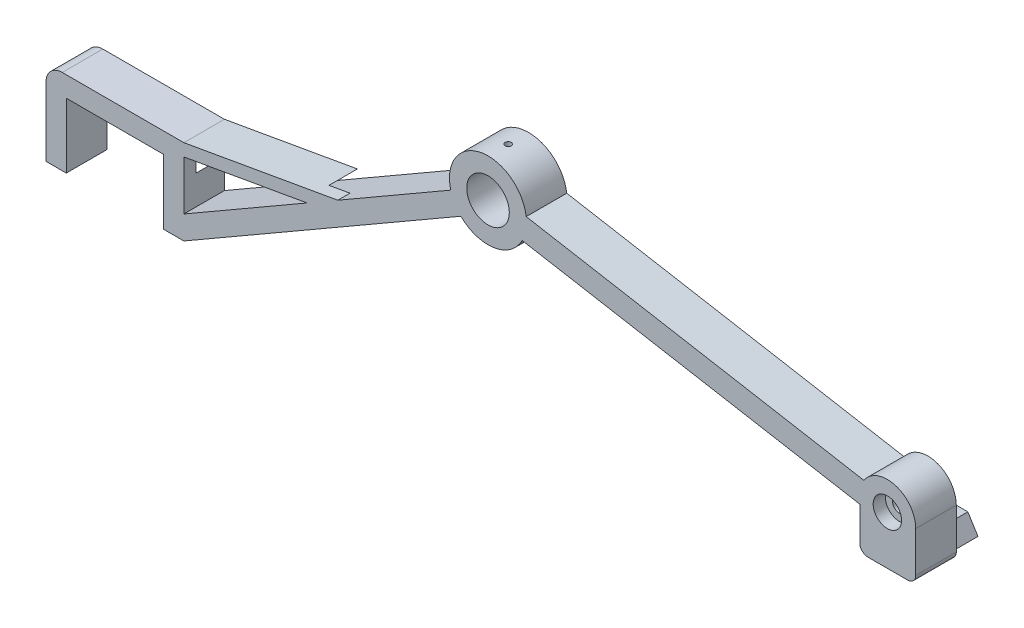
from build123d import *

# Parameters (mm, degrees)
SKICA1_R                 = 5.25
P_IDAT_VYSUNUT_M1_DEPTH  = 5
ZAOBLIT1_R               = 4
P_IDAT_VYSUNUT_M3_DEPTH  = 5
SKICA5_R                 = 4.25
SKICA5_R_2               = 1.75
P_IDAT_VYSUNUT_M4_DEPTH  = 1
SKICA8_R                 = 1.05
ODEBRAT_VYSUNUT_M3_DEPTH = 6
ODEBRAT_VYSUNUT_M4_DEPTH = 7
SKICA2_R                 = 1.75
ODEBRAT_VYSUNUT_M5_DEPTH = 10
SKICA10_R                = 3.5
ODEBRAT_VYSUNUT_M6_DEPTH = 3
ODEBRAT_START            = 50
SKICA11_R                = 0.75
ODEBRAT_VYSUNUT_M7_DEPTH = 10
P_IDAT_VYSUNUT_M5_DEPTH  = 10
P_IDAT_VYSUNUT_M6_DEPTH  = 8
ZAOBLIT2_R               = 2
ODEBRAT_VYSUNUT_M8_DEPTH = 7


with BuildPart() as part:
    # Skica1 → Přidat vysunutím1 (new body, symmetric)
    with BuildSketch(Plane.XY):
        with BuildLine():
            Line((0, 0), (0, 16))
            Line((0, 16), (24, 16))
            Line((24, 16), (24, 0))
            Line((24, 0), (29, 0))
            Line((29, 0), (97.312746067, 39.440382331))
            ThreePointArc((97.312746067, 39.440382331), (105.473420704, 36.802978572), (112.433277726, 41.81425579))
            Line((112.433277726, 41.81425579), (195.687578405, 27.134276321))
            ThreePointArc((195.687578405, 27.134276321), (209.374429572, 27.607666525), (196.674905514, 32.733686604))
            Line((196.674905514, 32.733686604), (113.420604835, 47.413666074))
            ThreePointArc((113.420604835, 47.413666074), (102.174688824, 55.511016714), (94.812746067, 43.77050935))
            Line((94.812746067, 43.77050935), (29, 5.773502692))
            Line((29, 5.773502692), (29, 21))
            Line((29, 21), (-5, 21))
            Line((-5, 21), (-5, 0))
            Line((-5, 0), (0, 0))
        make_face()
        with Locations((104, 46.188021535)):
            Circle(SKICA1_R, mode=Mode.SUBTRACT)
    extrude(amount=P_IDAT_VYSUNUT_M1_DEPTH, both=True)

    # Zaoblit1
    zaoblit1_edges = [part.edges().sort_by_distance(p)[0] for p in [
        (-5, 21, 0),
    ]]
    fillet(zaoblit1_edges, radius=ZAOBLIT1_R)

    # Skica4 → Přidat vysunutím3 (add, symmetric)
    with BuildSketch(Plane.XY):
        Polygon((29, 21), (66.969109888, 27.694978507), (59.37284323, 23.309271907), (29, 17.953720164), align=None)
    extrude(amount=P_IDAT_VYSUNUT_M3_DEPTH, both=True)

    # Skica5 → Přidat vysunutím4 (add)
    with BuildSketch(Plane.XY.offset(5)):
        with Locations((202.480775301, 28.823203768)):
            Circle(SKICA5_R)
        with Locations((202.480775301, 28.823203768)):
            Circle(SKICA5_R_2, mode=Mode.SUBTRACT)
    extrude(amount=P_IDAT_VYSUNUT_M4_DEPTH)

    # Skica8 → Odebrat vysunutím3 (cut)
    with BuildSketch(Plane.XZ):
        with Locations((-1.5, 0)):
            Circle(SKICA8_R)
        with Locations((25.5, 0)):
            Circle(SKICA8_R)
    extrude(amount=-ODEBRAT_VYSUNUT_M3_DEPTH, mode=Mode.SUBTRACT)

    # Skica9 → Odebrat vysunutím4 (cut)
    with BuildSketch(Plane.XY.offset(5)):
        Polygon((24, 16), (29, 16), (29, 13), (24, 8), align=None)
    extrude(amount=-ODEBRAT_VYSUNUT_M4_DEPTH, mode=Mode.SUBTRACT)

    # Skica2 → Odebrat vysunutím5 (cut)
    with BuildSketch(Plane.XY.offset(5)):
        with Locations((202.480775301, 28.823203768)):
            Circle(SKICA2_R)
    extrude(amount=-ODEBRAT_VYSUNUT_M5_DEPTH, mode=Mode.SUBTRACT)

    # Skica10 → Odebrat vysunutím6 (cut)
    with BuildSketch(Plane(origin=(0, 0, -5), x_dir=(-1, 0, 0), z_dir=(0, 0, -1))):
        with Locations((-202.480775301, 28.823203768)):
            Circle(SKICA10_R)
    extrude(amount=-ODEBRAT_VYSUNUT_M6_DEPTH, mode=Mode.SUBTRACT)


with BuildPart() as body_2:
    # Zrcadlit1: mirrored copy
    add(part.part.mirror(Plane(origin=(93.65445241, 28.310869093, -5), x_dir=(1, 0, 0), z_dir=(0, 0, -1))))

    # Skica11 → Odebrat vysunutím7 (cut)
    with BuildSketch(Plane(origin=(0, 0, 0), x_dir=(1, 0, 0), z_dir=(0, 1, 0)).offset(ODEBRAT_START)):
        with Locations((103.960302418, 10)):
            Circle(SKICA11_R)
    extrude(amount=ODEBRAT_VYSUNUT_M7_DEPTH, mode=Mode.SUBTRACT)

    # Skica12 → Přidat vysunutím5 (add)
    with BuildSketch(Plane(origin=(0, 0, -15), x_dir=(-1, 0, 0), z_dir=(0, 0, -1))):
        with BuildLine():
            Line((-209.480775301, 28.823203768), (-209.480775301, 16.823203768))
            Line((-209.480775301, 16.823203768), (-195.687578405, 16.823203768))
            Line((-195.687578405, 16.823203768), (-195.687578405, 27.134276321))
            ThreePointArc((-195.687578405, 27.134276321), (-203.331546047, 21.875096894), (-209.480775301, 28.823203768))
        make_face()
    extrude(amount=-P_IDAT_VYSUNUT_M5_DEPTH)

    # Skica13 → Přidat vysunutím6 (add)
    with BuildSketch(Plane(origin=(0, 0, -15), x_dir=(-1, 0, 0), z_dir=(0, 0, -1))):
        Polygon((-204.334176853, 20.823203768), (-200.834176853, 20.823203768), (-198.334176853, 16.823203768), (-206.834176853, 16.823203768), align=None)
    extrude(amount=P_IDAT_VYSUNUT_M6_DEPTH)

    # Zaoblit2
    zaoblit2_edges = [body_2.edges().sort_by_distance(p)[0] for p in [
        (195.687578405, 16.823203768, -10),
        (209.480775301, 16.823203768, -10),
    ]]
    fillet(zaoblit2_edges, radius=ZAOBLIT2_R)

    # Skica14 → Odebrat vysunutím8 (cut)
    with BuildSketch(Plane(origin=(0, 0, -15), x_dir=(-1, 0, 0), z_dir=(0, 0, -1))):
        Polygon((-59.37284323, 23.309271907), (-66.969109888, 27.694978507), (-61.786216453, 26.781094556), (-54.189949795, 22.395387956), align=None)
    extrude(amount=-ODEBRAT_VYSUNUT_M8_DEPTH, mode=Mode.SUBTRACT)


solid = body_2.part
